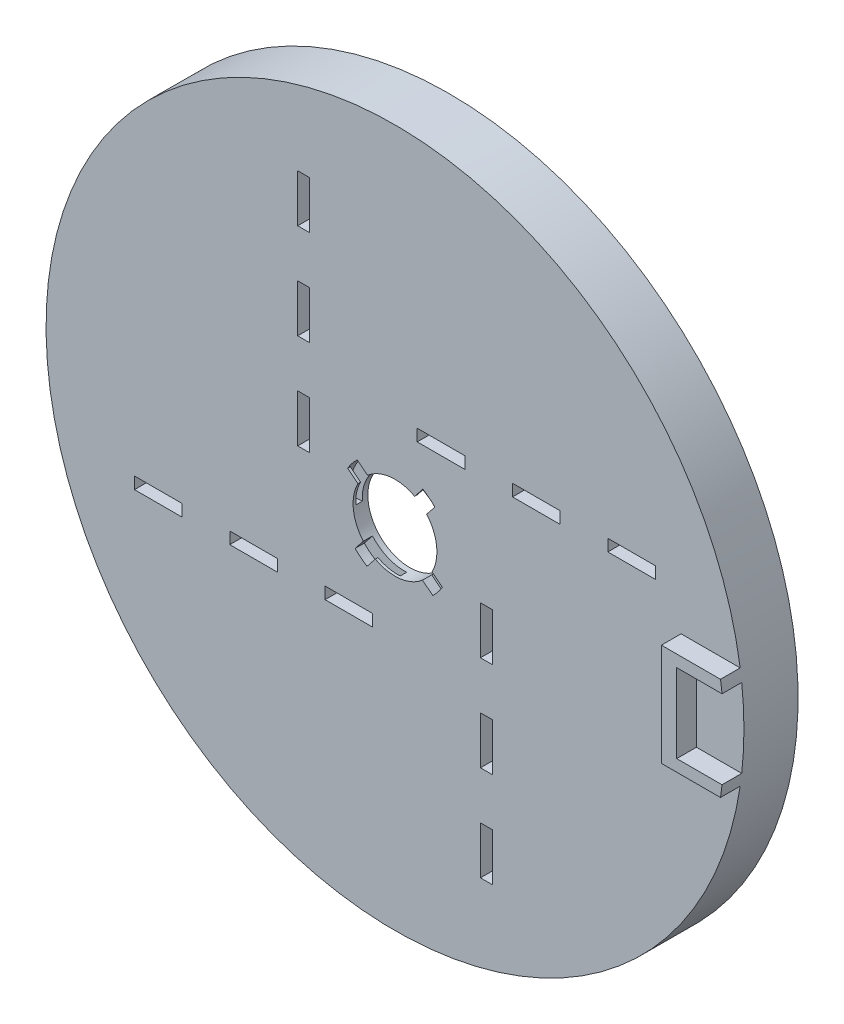
from build123d import *

# Parameters (mm, degrees)
SKETCH1_W           = 200
SKETCH1_H           = 200
SKETCH1_R           = 10.65
BOSS_EXTRUDE1_DEPTH = 3.75
CUT_EXTRUDE4_START  = -1.5
CUT_EXTRUDE4_DEPTH  = 0.825
CUT_EXTRUDE5_DEPTH  = 3.325
CIRPATTERN1_COUNT   = 4
SKETCH5_W           = 12.1
SKETCH5_H           = 3
CUT_EXTRUDE6_DEPTH  = 10
CIRPATTERN2_COUNT   = 4
SKETCH6_W           = 200
SKETCH6_H           = 200.182674684
SKETCH6_R           = 88.610994186
CUT_EXTRUDE7_DEPTH  = 4.75
SKETCH8_R           = 86.110994186
SKETCH8_R_2         = 84.610994186
BOSS_EXTRUDE2_DEPTH = 13.75
BOSS_EXTRUDE3_DEPTH = 5


with BuildPart() as part:
    # Sketch1 → Boss-Extrude1 (new body)
    with BuildSketch(Plane.XY):
        Rectangle(SKETCH1_W, SKETCH1_H)
        Circle(SKETCH1_R, mode=Mode.SUBTRACT)
    extrude(amount=-BOSS_EXTRUDE1_DEPTH)

    # Sketch2 → Cut-Extrude4 (cut, symmetric)
    with BuildSketch(Plane.XY.offset(CUT_EXTRUDE4_START)):
        with BuildLine():
            Line((8.682868236, 10.918346907), (6.628856395, 8.335512155))
            ThreePointArc((6.628856395, 8.335512155), (3.815515862, 9.943054798), (0.648987911, 10.63020765))
            ThreePointArc((0.648987911, 10.63020765), (0.324644823, 10.645050763), (0, 10.65))
            ThreePointArc((0, 10.65), (-0.324644823, 10.645050763), (-0.648987911, 10.63020765))
            Line((-0.648987911, 10.63020765), (-0.850082756, 13.92407481))
            ThreePointArc((-0.850082756, 13.92407481), (-0.425238994, 13.943517196), (0, 13.95))
            ThreePointArc((0, 13.95), (0.425238994, 13.943517196), (0.850082756, 13.92407481))
            ThreePointArc((0.850082756, 13.92407481), (4.997788382, 13.024001355), (8.682868236, 10.918346907))
        make_face()
    cut_extrude4 = extrude(amount=CUT_EXTRUDE4_DEPTH, both=True, mode=Mode.SUBTRACT)

    # Sketch4 → Cut-Extrude5 (cut, through all)
    with BuildSketch(Plane.XY.offset(-2.325)):
        with BuildLine():
            Line((5.000342926, 9.403141529), (7.076920348, 12.021634597))
            ThreePointArc((7.076920348, 12.021634597), (7.89918002, 11.498063098), (8.682868236, 10.918346907))
            ThreePointArc((8.682868236, 10.918346907), (9.424158272, 10.285316761), (10.119430429, 9.602063726))
            Line((10.119430429, 9.602063726), (8.035757001, 6.989213791))
            ThreePointArc((8.035757001, 6.989213791), (7.363141404, 7.694585672), (6.628856395, 8.335512155))
            ThreePointArc((6.628856395, 8.335512155), (5.839051921, 8.906625212), (5.000342926, 9.403141529))
        make_face()
    cut_extrude5 = extrude(amount=CUT_EXTRUDE5_DEPTH, mode=Mode.SUBTRACT)

    # CirPattern1: Cut-Extrude4, Cut-Extrude5 ×4 about axis
    cirpattern1_axis = Axis((0, 0, 0), (0, 0, 1))
    for i in range(1, CIRPATTERN1_COUNT):
        add(cut_extrude4.rotate(cirpattern1_axis, i * 360 / CIRPATTERN1_COUNT), mode=Mode.SUBTRACT)
        add(cut_extrude5.rotate(cirpattern1_axis, i * 360 / CIRPATTERN1_COUNT), mode=Mode.SUBTRACT)

    # Sketch5 → Cut-Extrude6 (cut)
    with BuildSketch(Plane.XY):
        with Locations((35.9, 23.2)):
            Rectangle(SKETCH5_W, SKETCH5_H)
        with Locations((60.1, 23.2)):
            Rectangle(SKETCH5_W, SKETCH5_H)
        with Locations((11.7, 23.2)):
            Rectangle(SKETCH5_W, SKETCH5_H)
    cut_extrude6 = extrude(amount=-CUT_EXTRUDE6_DEPTH, mode=Mode.SUBTRACT)

    # CirPattern2: Cut-Extrude6 ×4 about axis
    cirpattern2_axis = Axis((0, 0, 0), (0, 0, 1))
    for i in range(1, CIRPATTERN2_COUNT):
        add(cut_extrude6.rotate(cirpattern2_axis, i * 360 / CIRPATTERN2_COUNT), mode=Mode.SUBTRACT)

    # Sketch6 → Cut-Extrude7 (cut, through all)
    with BuildSketch(Plane(origin=(0, 0, -3.75), x_dir=(-1, 0, 0), z_dir=(0, 0, -1))):
        with Locations((0, 0.091337342)):
            Rectangle(SKETCH6_W, SKETCH6_H)
        Circle(SKETCH6_R, mode=Mode.SUBTRACT)
    extrude(amount=-CUT_EXTRUDE7_DEPTH, mode=Mode.SUBTRACT)

    # Sketch8 → Boss-Extrude2 (add)
    with BuildSketch(Plane.XY):
        Circle(SKETCH8_R)
        Circle(SKETCH8_R_2, mode=Mode.SUBTRACT)
        with BuildLine():
            Line((-88.273802601, 7.722957014), (-86.779510554, 7.5922234))
            ThreePointArc((-86.779510554, 7.5922234), (87.110994186, 0), (-86.779510554, -7.5922234))
            Line((-86.779510554, -7.5922234), (-88.273802601, -7.722957014))
            ThreePointArc((-88.273802601, -7.722957014), (88.610994186, 0), (-88.273802601, 7.722957014))
        make_face()
    extrude(amount=-BOSS_EXTRUDE2_DEPTH)

    # Sketch11 → Boss-Extrude3 (add)
    with BuildSketch(Plane.XY):
        with BuildLine():
            Line((76.545964234, -10), (88.044922004, -10))
            ThreePointArc((88.044922004, -10), (87.861366557, -11.501676291), (87.652200718, -13))
            Line((87.652200718, -13), (72.652200718, -13))
            Line((72.652200718, -13), (72.652200718, 13))
            Line((72.652200718, 13), (87.652200718, 13))
            ThreePointArc((87.652200718, 13), (87.861366557, 11.501676291), (88.044922004, 10))
            Line((88.044922004, 10), (76.545964234, 10))
            Line((76.545964234, 10), (76.545964234, -10))
        make_face()
    extrude(amount=BOSS_EXTRUDE3_DEPTH)


solid = part.part
